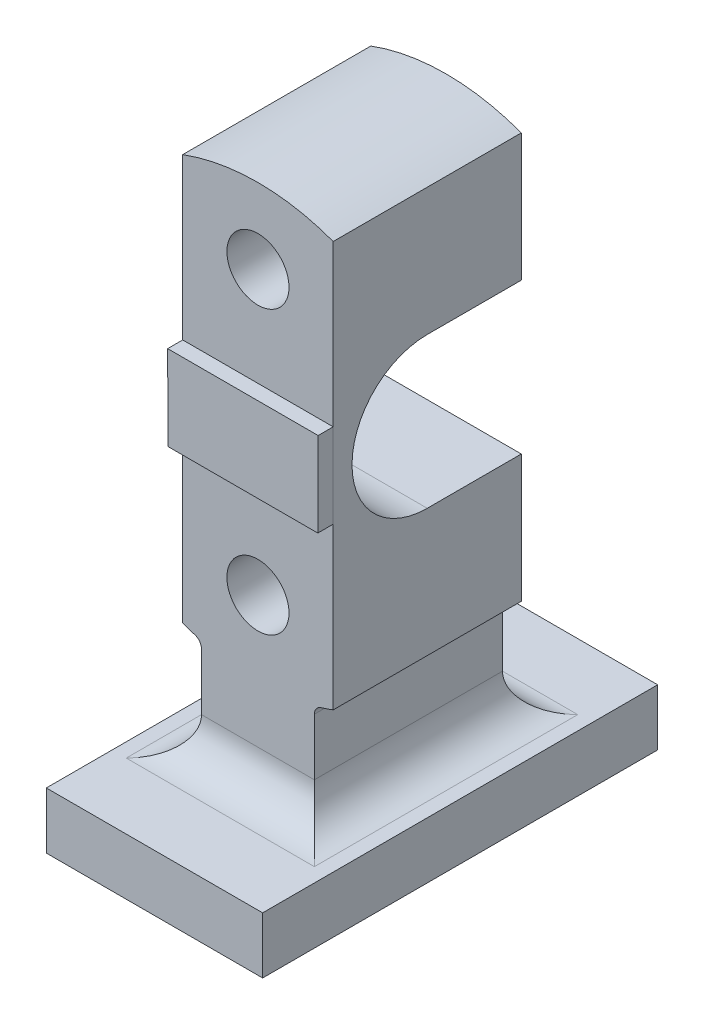
from build123d import *

# Parameters (mm, degrees)
SKETCH1_R           = 16.5
BOSS_EXTRUDE1_DEPTH = 50
SKETCH4_W           = 115
SKETCH4_H           = 30
BOSS_EXTRUDE2_DEPTH = 105
FILLET1_R           = 20
FILLET2_R           = 20
FILLET3_R           = 20
FILLET4_R           = 20
FILLET5_R           = 5
CUT_EXTRUDE2_DEPTH  = 138
BOSS_EXTRUDE4_DEPTH = 8


with BuildPart() as part:
    # Sketch1 → Boss-Extrude1 (new body, symmetric)
    with BuildSketch(Plane.XY):
        with BuildLine():
            Line((40, -107.819293264), (40, 0))
            Line((40, 0), (-40, 0))
            Line((-40, 0), (-40, -107.819293264))
            ThreePointArc((-40, -107.819293264), (-35.036523196, -109.532835453), (-30, -111.018016556))
            Line((-30, -111.018016556), (-30, -165))
            Line((-30, -165), (30, -165))
            Line((30, -165), (30, -111.018016556))
            ThreePointArc((30, -111.018016556), (35.036523196, -109.532835453), (40, -107.819293264))
        make_face()
        with Locations((0, -75)):
            Circle(SKETCH1_R, mode=Mode.SUBTRACT)
        with BuildLine():
            Line((-40, 0), (40, 0))
            Line((40, 0), (40, 107.819293264))
            ThreePointArc((40, 107.819293264), (0, 115), (-40, 107.819293264))
            Line((-40, 107.819293264), (-40, 0))
        make_face()
        with Locations((0, 75)):
            Circle(SKETCH1_R, mode=Mode.SUBTRACT)
    extrude(amount=BOSS_EXTRUDE1_DEPTH, both=True)

    # Sketch4 → Boss-Extrude2 (add, symmetric)
    with BuildSketch(Plane.XY):
        with Locations((0, -180)):
            Rectangle(SKETCH4_W, SKETCH4_H)
    extrude(amount=BOSS_EXTRUDE2_DEPTH, both=True)

    # Fillet1
    fillet1_edges = [part.edges().sort_by_distance(p)[0] for p in [
        (-30, -165, 0),
    ]]
    fillet(fillet1_edges, radius=FILLET1_R)

    # Fillet2
    fillet2_edges = [part.edges().sort_by_distance(p)[0] for p in [
        (0, -165, 50),
    ]]
    fillet(fillet2_edges, radius=FILLET2_R)

    # Fillet3
    fillet3_edges = [part.edges().sort_by_distance(p)[0] for p in [
        (0, -165, -50),
    ]]
    fillet(fillet3_edges, radius=FILLET3_R)

    # Fillet4
    fillet4_edges = [part.edges().sort_by_distance(p)[0] for p in [
        (30, -165, 0),
    ]]
    fillet(fillet4_edges, radius=FILLET4_R)

    # Fillet5
    fillet5_edges = [part.edges().sort_by_distance(p)[0] for p in [
        (-30, -111.018016556, 0),
        (30, -111.018016556, 0),
    ]]
    fillet(fillet5_edges, radius=FILLET5_R)

    # Sketch6 → Cut-Extrude2 (cut)
    with BuildSketch(Plane.ZY.offset(40)):
        with BuildLine():
            Line((0, 40), (-50, 40))
            Line((-50, 40), (-50, -40))
            Line((-50, -40), (0, -40))
            ThreePointArc((0, -40), (40, 0), (0, 40))
        make_face()
    extrude(amount=-CUT_EXTRUDE2_DEPTH, mode=Mode.SUBTRACT)

    # Sketch8 → Boss-Extrude4 (add)
    with BuildSketch(Plane.XY.offset(50)):
        Polygon((-39.81738938, -22.5), (-40, 22.5), (40, 22.5), (39.81738938, -22.5), align=None)
    extrude(amount=BOSS_EXTRUDE4_DEPTH)


solid = part.part
